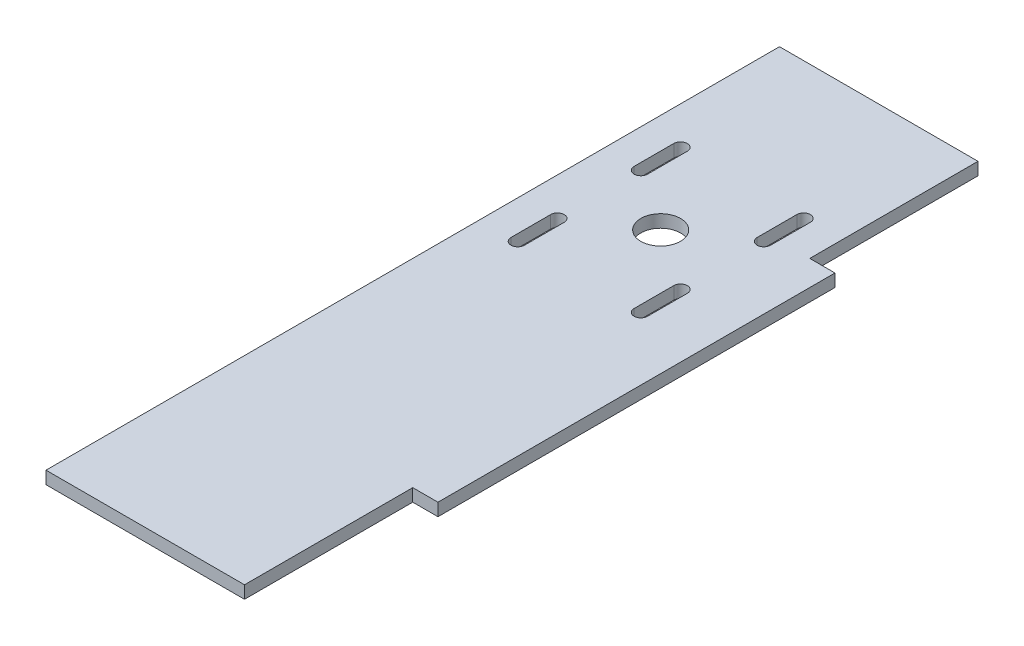
from build123d import *

# Parameters (mm, degrees)
BOSS_EXTRUDE1_DEPTH  = 3.175
SKETCH2_R            = 5
CUT_EXTRUDE1_DEPTH   = 146.820244651
M3_CLEARANCE_HOLE1_D = 3.4
CUT_EXTRUDE2_DEPTH   = 146.820244651


with BuildPart() as part:
    # Sketch1 → Boss-Extrude1 (new body)
    with BuildSketch(Plane(origin=(0, 0, 0), x_dir=(1, 0, 0), z_dir=(0, 1, 0))):
        Polygon((-25, 0), (-25, 42.375), (25, 42.375), (25, 0), (31.35, 0), (31.35, -100), (25, -100), (25, -142.375), (-25, -142.375), (-25, -100), align=None)
    extrude(amount=BOSS_EXTRUDE1_DEPTH)

    # Sketch2 → Cut-Extrude1 (cut, through all)
    with BuildSketch(Plane(origin=(0, 3.175, 0), x_dir=(1, 0, 0), z_dir=(0, 1, 0))):
        with Locations(Location((0, -12.55, 0), (0, 0, 270))):
            Circle(SKETCH2_R)
    extrude(amount=-CUT_EXTRUDE1_DEPTH, mode=Mode.SUBTRACT)

    # M3 Clearance Hole1 (through all)
    with Locations(Plane(origin=(0, 3.175, 0), x_dir=(1, 0, 0), z_dir=(0, 1, 0))):
        with Locations((-15.5, 2.95), (15.5, 2.95), (15.5, -28.05), (-15.5, -28.05)):
            Hole(M3_CLEARANCE_HOLE1_D / 2)

    # Sketch7 → Cut-Extrude2 (cut, through all)
    with BuildSketch(Plane(origin=(0, 3.175, 0), x_dir=(1, 0, 0), z_dir=(0, 1, 0))):
        with BuildLine():
            Line((17.2, 7.95), (17.2, -2.05))
            ThreePointArc((17.2, -2.05), (15.5, -3.75), (13.8, -2.05))
            Line((13.8, -2.05), (13.8, 7.95))
            ThreePointArc((13.8, 7.95), (15.5, 9.65), (17.2, 7.95))
        make_face()
        with BuildLine():
            Line((-13.8, 7.95), (-13.8, -2.05))
            ThreePointArc((-13.8, -2.05), (-15.5, -3.75), (-17.2, -2.05))
            Line((-17.2, -2.05), (-17.2, 7.95))
            ThreePointArc((-17.2, 7.95), (-15.5, 9.65), (-13.8, 7.95))
        make_face()
        with BuildLine():
            Line((17.2, -33.05), (17.2, -23.05))
            ThreePointArc((17.2, -23.05), (15.5, -21.35), (13.8, -23.05))
            Line((13.8, -23.05), (13.8, -33.05))
            ThreePointArc((13.8, -33.05), (15.5, -34.75), (17.2, -33.05))
        make_face()
        with BuildLine():
            Line((-13.8, -33.05), (-13.8, -23.05))
            ThreePointArc((-13.8, -23.05), (-15.5, -21.35), (-17.2, -23.05))
            Line((-17.2, -23.05), (-17.2, -33.05))
            ThreePointArc((-17.2, -33.05), (-15.5, -34.75), (-13.8, -33.05))
        make_face()
    extrude(amount=-CUT_EXTRUDE2_DEPTH, mode=Mode.SUBTRACT)


solid = part.part
